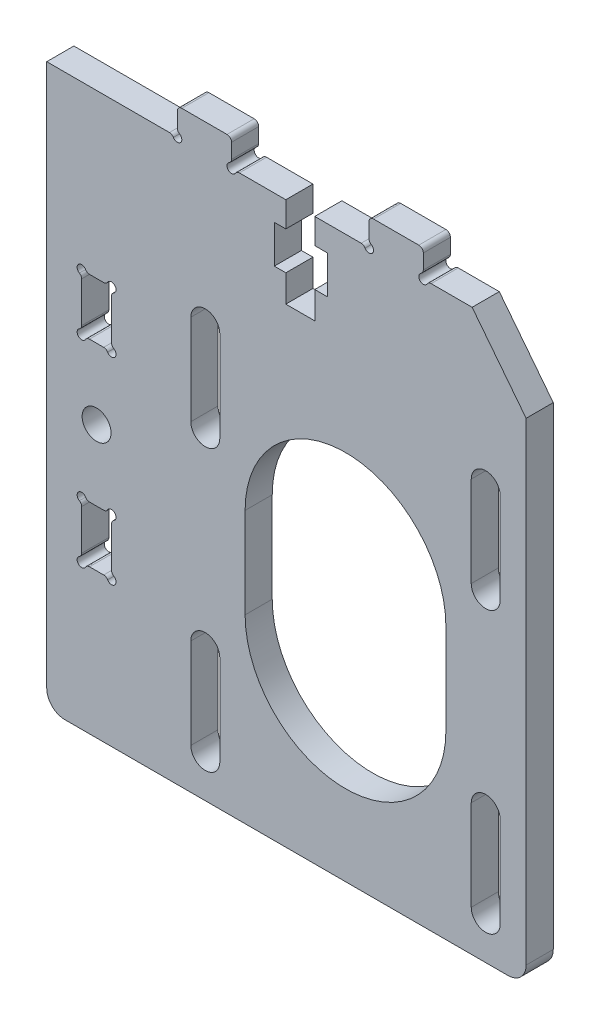
from build123d import *

# Parameters (mm, degrees)
MODEL_R             = 1.6
BOSS_EXTRUDE1_DEPTH = 3


with BuildPart() as part:
    # Model → Boss-Extrude1 (new body)
    with BuildSketch(Plane.XY):
        with BuildLine():
            Line((295.043822464, 218.133419689), (281.478366665, 218.133419689))
            Line((281.478366665, 218.133419689), (281.478366665, 158.133416479))
            ThreePointArc((281.478366665, 158.133416479), (282.064153103, 156.719202917), (283.478366665, 156.133416479))
            Line((283.478366665, 156.133416479), (332.478366665, 156.133416479))
            ThreePointArc((332.478366665, 156.133416479), (333.892580227, 156.719202917), (334.478366665, 158.133416479))
            Line((334.478366665, 158.133416479), (334.478366665, 210.48904049))
            Line((334.478366665, 210.48904049), (328.509839464, 218.133396046))
            Line((328.509839464, 218.133396046), (323.975870464, 218.133396046))
            ThreePointArc((323.975870464, 218.133396046), (323.725870171, 218.066408731), (323.542857332, 217.883395759))
            ThreePointArc((323.542857332, 217.883395759), (322.756291514, 217.779840053), (322.859842674, 218.566406469))
            ThreePointArc((322.859842674, 218.566406469), (323.042854191, 218.749419176), (323.109840891, 218.999418473))
            Line((323.109840891, 218.999418473), (323.109840891, 220.633447473))
            ThreePointArc((323.109840891, 220.633447473), (322.963394282, 220.987000863), (322.609840891, 221.133447473))
            Line((322.609840891, 221.133447473), (317.609843891, 221.133447473))
            ThreePointArc((317.609843891, 221.133447473), (317.256293472, 220.987003641), (317.109844085, 220.633455522))
            Line((317.109844085, 220.633455522), (317.109844085, 218.999428522))
            ThreePointArc((317.109844085, 218.999428522), (317.176831025, 218.749428628), (317.35984329, 218.566415765))
            ThreePointArc((317.35984329, 218.566415765), (317.463395273, 217.779850295), (316.676829874, 217.883402813))
            ThreePointArc((316.676829874, 217.883402813), (316.49381775, 218.066414713), (316.243818787, 218.133402112))
            Line((316.243818787, 218.133402112), (311.109839721, 218.133402112))
            Line((311.109839721, 218.133402112), (311.109839721, 215.333404229))
            Line((311.109839721, 215.333404229), (312.534860417, 215.333404229))
            Line((312.534860417, 215.333404229), (312.534860417, 211.133417963))
            Line((312.534860417, 211.133417963), (311.109850498, 211.133417963))
            Line((311.109850498, 211.133417963), (311.109850498, 208.133417963))
            Line((311.109850498, 208.133417963), (307.909850498, 208.133417963))
            Line((307.909850498, 208.133417963), (307.909850498, 211.133417963))
            Line((307.909850498, 211.133417963), (306.634859186, 211.133417963))
            Line((306.634859186, 211.133417963), (306.634859186, 215.333417963))
            Line((306.634859186, 215.333417963), (307.909850498, 215.333417963))
            Line((307.909850498, 215.333417963), (307.909850498, 218.133417963))
            Line((307.909850498, 218.133417963), (302.775874676, 218.133417963))
            ThreePointArc((302.775874676, 218.133417963), (302.525874676, 218.066430665), (302.342861974, 217.883417963))
            ThreePointArc((302.342861974, 217.883417963), (301.556296087, 217.779862777), (301.659847768, 218.566429125))
            ThreePointArc((301.659847768, 218.566429125), (301.842859406, 218.749441711), (301.909846272, 218.999440963))
            Line((301.909846272, 218.999440963), (301.909846272, 220.633469963))
            ThreePointArc((301.909846272, 220.633469963), (301.763399662, 220.987023354), (301.409846272, 221.133469963))
            Line((301.409846272, 221.133469963), (296.409849272, 221.133469963))
            ThreePointArc((296.409849272, 221.133469963), (296.056295709, 220.987026085), (295.909846369, 220.633474785))
            Line((295.909846369, 220.633474785), (295.909846369, 218.999447785))
            ThreePointArc((295.909846369, 218.999447785), (295.976833795, 218.749448021), (296.159846417, 218.566435514))
            ThreePointArc((296.159846417, 218.566435514), (296.263399931, 217.779870247), (295.47683433, 217.883421233))
            ThreePointArc((295.47683433, 217.883421233), (295.293821724, 218.066432851), (295.043822464, 218.133419689))
        make_face()
        with Locations((286.989833469, 186.133406309)):
            Circle(MODEL_R, mode=Mode.SUBTRACT)
        with BuildLine():
            Line((325.609838719, 176.133405309), (325.609838719, 186.133405309))
            ThreePointArc((325.609838719, 186.133405309), (314.509838719, 197.233405309), (303.409838719, 186.133405309))
            Line((303.409838719, 186.133405309), (303.409838719, 176.133405309))
            ThreePointArc((303.409838719, 176.133405309), (314.509838719, 165.033405309), (325.609838719, 176.133405309))
        make_face(mode=Mode.SUBTRACT)
        with BuildLine():
            Line((331.609838719, 160.633405309), (331.609838719, 170.636460624))
            ThreePointArc((331.609838719, 170.636460624), (330.009838719, 172.236460624), (328.409838719, 170.636460624))
            Line((328.409838719, 170.636460624), (328.409838719, 160.633405309))
            ThreePointArc((328.409838719, 160.633405309), (330.009838719, 159.033405309), (331.609838719, 160.633405309))
        make_face(mode=Mode.SUBTRACT)
        with BuildLine():
            Line((331.609838719, 201.633405309), (331.609838719, 191.630349994))
            ThreePointArc((331.609838719, 191.630349994), (330.009838719, 190.030349994), (328.409838719, 191.630349994))
            Line((328.409838719, 191.630349994), (328.409838719, 201.633405309))
            ThreePointArc((328.409838719, 201.633405309), (330.009838719, 203.233405309), (331.609838719, 201.633405309))
        make_face(mode=Mode.SUBTRACT)
        with BuildLine():
            Line((297.409838719, 160.633405309), (297.409838719, 170.636460624))
            ThreePointArc((297.409838719, 170.636460624), (299.009838719, 172.236460624), (300.609838719, 170.636460624))
            Line((300.609838719, 170.636460624), (300.609838719, 160.633405309))
            ThreePointArc((300.609838719, 160.633405309), (299.009838719, 159.033405309), (297.409838719, 160.633405309))
        make_face(mode=Mode.SUBTRACT)
        with BuildLine():
            Line((297.409838719, 201.633405309), (297.409838719, 191.630349994))
            ThreePointArc((297.409838719, 191.630349994), (299.009838719, 190.030349994), (300.609838719, 191.630349994))
            Line((300.609838719, 191.630349994), (300.609838719, 201.633405309))
            ThreePointArc((300.609838719, 201.633405309), (299.009838719, 203.233405309), (297.409838719, 201.633405309))
        make_face(mode=Mode.SUBTRACT)
        with BuildLine():
            Line((288.639792166, 173.001169926), (288.639792166, 177.469119926))
            ThreePointArc((288.639792166, 177.469119926), (288.706781285, 177.719120392), (288.889796147, 177.902132238))
            ThreePointArc((288.889796147, 177.902132238), (288.993345727, 178.688698026), (288.206780642, 178.585143097))
            ThreePointArc((288.206780642, 178.585143097), (288.023768466, 178.402130146), (287.773768823, 178.335142269))
            Line((287.773768823, 178.335142269), (286.205898823, 178.335142269))
            ThreePointArc((286.205898823, 178.335142269), (285.955899571, 178.402129135), (285.772886985, 178.585140772))
            ThreePointArc((285.772886985, 178.585140772), (284.986321396, 178.688691846), (285.089874823, 177.902126567))
            ThreePointArc((285.089874823, 177.902126567), (285.272887674, 177.719113607), (285.339874823, 177.469113269))
            Line((285.339874823, 177.469113269), (285.339874823, 173.001163269))
            ThreePointArc((285.339874823, 173.001163269), (285.272887957, 172.751164017), (285.089876319, 172.568151431))
            ThreePointArc((285.089876319, 172.568151431), (284.986324638, 171.781585083), (285.772890525, 171.885140269))
            ThreePointArc((285.772890525, 171.885140269), (285.955903052, 172.06815287), (286.205902823, 172.135140269))
            Line((286.205902823, 172.135140269), (287.773770823, 172.135140269))
            ThreePointArc((287.773770823, 172.135140269), (288.023770203, 172.068153881), (288.206783139, 171.885142594))
            ThreePointArc((288.206783139, 171.885142594), (288.993349685, 171.781592418), (288.889792994, 172.568158106))
            ThreePointArc((288.889792994, 172.568158106), (288.706780043, 172.751170283), (288.639792166, 173.001169926))
        make_face(mode=Mode.SUBTRACT)
        with BuildLine():
            Line((285.339870115, 199.26564477), (285.339870115, 194.79769477))
            ThreePointArc((285.339870115, 194.79769477), (285.272883249, 194.547695518), (285.089871611, 194.364682932))
            ThreePointArc((285.089871611, 194.364682932), (284.986320538, 193.578117343), (285.772885817, 193.68167077))
            ThreePointArc((285.772885817, 193.68167077), (285.955898344, 193.864683371), (286.205898115, 193.93167077))
            Line((286.205898115, 193.93167077), (287.773766115, 193.93167077))
            ThreePointArc((287.773766115, 193.93167077), (288.023765495, 193.864684382), (288.206778431, 193.681673095))
            ThreePointArc((288.206778431, 193.681673095), (288.993344977, 193.578122919), (288.889788286, 194.364688607))
            ThreePointArc((288.889788286, 194.364688607), (288.706775085, 194.547701217), (288.639787458, 194.797701427))
            Line((288.639787458, 194.797701427), (288.639787458, 199.265650427))
            ThreePointArc((288.639787458, 199.265650427), (288.70677658, 199.515650897), (288.889791447, 199.698662743))
            ThreePointArc((288.889791447, 199.698662743), (288.993341016, 200.485228531), (288.206775935, 200.381673598))
            ThreePointArc((288.206775935, 200.381673598), (288.023763758, 200.198660647), (287.773764115, 200.13167277))
            Line((287.773764115, 200.13167277), (286.205894115, 200.13167277))
            ThreePointArc((286.205894115, 200.13167277), (285.955894863, 200.198659636), (285.772882277, 200.381671273))
            ThreePointArc((285.772882277, 200.381671273), (284.986316688, 200.485222347), (285.089870115, 199.698657068))
            ThreePointArc((285.089870115, 199.698657068), (285.272882716, 199.515644541), (285.339870115, 199.26564477))
        make_face(mode=Mode.SUBTRACT)
    extrude(amount=BOSS_EXTRUDE1_DEPTH)


solid = part.part
